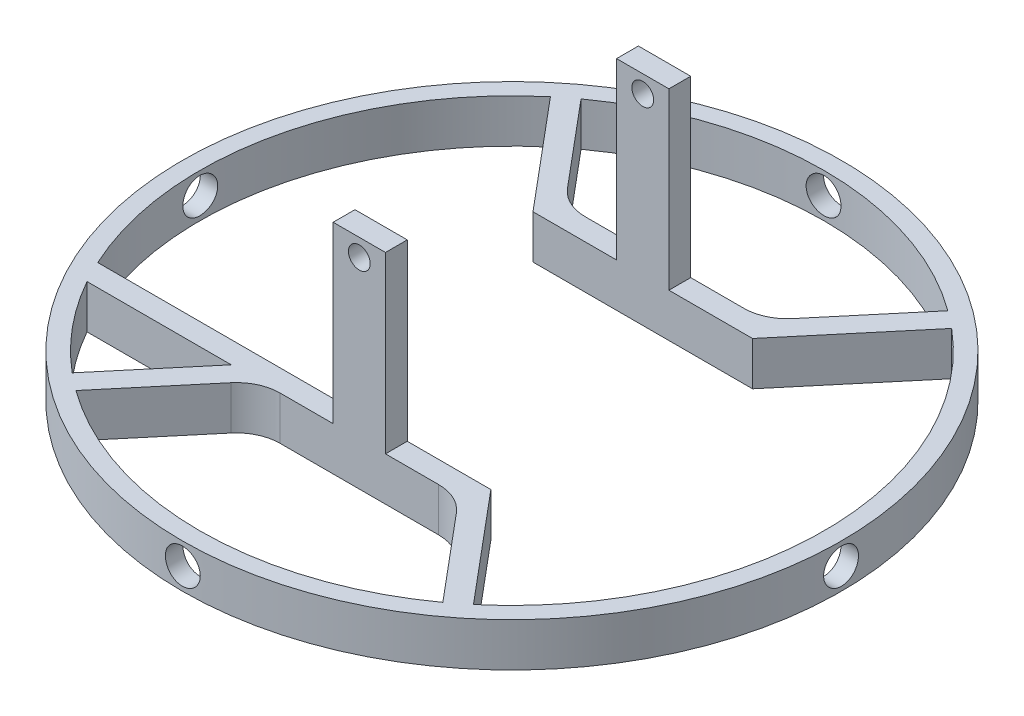
from build123d import *

# Parameters (mm, degrees)
CROQUIS2_R                 = 37.79
SALIENTE_EXTRUIR1_DEPTH    = 5
CROQUIS4_W                 = 6
CROQUIS4_H                 = 25
SALIENTE_EXTRUIR3_DEPTH    = 2.5
CROQUIS5_R                 = 1.25
CORTAR_EXTRUIR1_DEPTH      = 21.29
CORTAR_EXTRUIR1_DEPTH_BACK = 56.29
REDONDEO1_R                = 5
CORTAR_EXTRUIR2_START      = 50
CROQUIS6_R                 = 2
CORTAR_EXTRUIR2_DEPTH      = 17
MATRIZC1_COUNT             = 4
SALIENTE_EXTRUIR5_DEPTH    = 5


with BuildPart() as part:
    # Croquis2 → Saliente-Extruir1 (new body)
    with BuildSketch(Plane(origin=(0, 0, 0), x_dir=(1, 0, 0), z_dir=(0, 1, 0))):
        Circle(CROQUIS2_R)
        with BuildLine():
            Line((-12.586494468, 15), (12.586494468, 15))
            Line((12.586494468, 15), (23.005368551, 27.416730619))
            ThreePointArc((23.005368551, 27.416730619), (35.79, 0), (23.005368551, -27.416730619))
            Line((23.005368551, -27.416730619), (12.586494468, -15))
            Line((12.586494468, -15), (-12.586494468, -15))
            Line((-12.586494468, -15), (-23.005368551, -27.416730619))
            ThreePointArc((-23.005368551, -27.416730619), (-35.79, 0), (-23.005368551, 27.416730619))
            Line((-23.005368551, 27.416730619), (-12.586494468, 15))
        make_face(mode=Mode.SUBTRACT)
        with BuildLine():
            Line((-11.420725322, 17.5), (-21.034063882, 28.956730765))
            ThreePointArc((-21.034063882, 28.956730765), (0, 35.79), (21.034063882, 28.956730765))
            Line((21.034063882, 28.956730765), (11.420725322, 17.5))
            Line((11.420725322, 17.5), (-11.420725322, 17.5))
        make_face(mode=Mode.SUBTRACT)
        with BuildLine():
            ThreePointArc((21.034063882, -28.956730765), (0, -35.79), (-21.034063882, -28.956730765))
            Line((-21.034063882, -28.956730765), (-11.420725322, -17.5))
            Line((-11.420725322, -17.5), (11.420725322, -17.5))
            Line((11.420725322, -17.5), (21.034063882, -28.956730765))
        make_face(mode=Mode.SUBTRACT)
    extrude(amount=SALIENTE_EXTRUIR1_DEPTH)

    # Croquis4 → Saliente-Extruir3 (add)
    with BuildSketch(Plane.XY.offset(15)):
        with Locations((0, 12.5)):
            Rectangle(CROQUIS4_W, CROQUIS4_H)
    saliente_extruir3 = extrude(amount=SALIENTE_EXTRUIR3_DEPTH)

    # Simetría1: Saliente-Extruir3 across plane
    add(saliente_extruir3.mirror(Plane.XY))

    # Croquis5 → Cortar-Extruir1 (cut, two sides)
    with BuildSketch(Plane(origin=(0, 0, -17.5), x_dir=(-1, 0, 0), z_dir=(0, 0, -1))) as cortar_extruir1_sk:
        with Locations((0, 23)):
            Circle(CROQUIS5_R)
    extrude(amount=CORTAR_EXTRUIR1_DEPTH, mode=Mode.SUBTRACT)
    extrude(cortar_extruir1_sk.sketch, amount=-CORTAR_EXTRUIR1_DEPTH_BACK, mode=Mode.SUBTRACT)

    # Redondeo1
    redondeo1_edges = [part.edges().sort_by_distance(p)[0] for p in [
        (-11.420725322, 2.5, -17.5),
        (11.420725322, 2.5, -17.5),
        (11.420725322, 2.5, 17.5),
        (-11.420725322, 2.5, 17.5),
    ]]
    fillet(redondeo1_edges, radius=REDONDEO1_R)

    # Croquis6 → Cortar-Extruir2 (cut)
    with BuildSketch(Plane.XY.offset(CORTAR_EXTRUIR2_START)):
        with Locations((0, 2.5)):
            Circle(CROQUIS6_R)
    cortar_extruir2 = extrude(amount=-CORTAR_EXTRUIR2_DEPTH, mode=Mode.SUBTRACT)

    # MatrizC1: Cortar-Extruir2 ×4 about axis
    matrizc1_axis = Axis((0, 0, 0), (0, -1, 0))
    for i in range(1, MATRIZC1_COUNT):
        add(cortar_extruir2.rotate(matrizc1_axis, i * 360 / MATRIZC1_COUNT), mode=Mode.SUBTRACT)

    # Croquis8 → Saliente-Extruir5 (add)
    with BuildSketch(Plane(origin=(0, 5, 0), x_dir=(1, 0, 0), z_dir=(0, 1, 0))):
        with BuildLine():
            Line((-14.684243546, -17.5), (-12.586494468, -15))
            Line((-12.586494468, -15), (-32.494985767, -15))
            ThreePointArc((-32.494985767, -15), (-31.881892303, -16.26250421), (-31.219770979, -17.5))
            Line((-31.219770979, -17.5), (-14.684243546, -17.5))
        make_face()
    extrude(amount=-SALIENTE_EXTRUIR5_DEPTH)


solid = part.part
